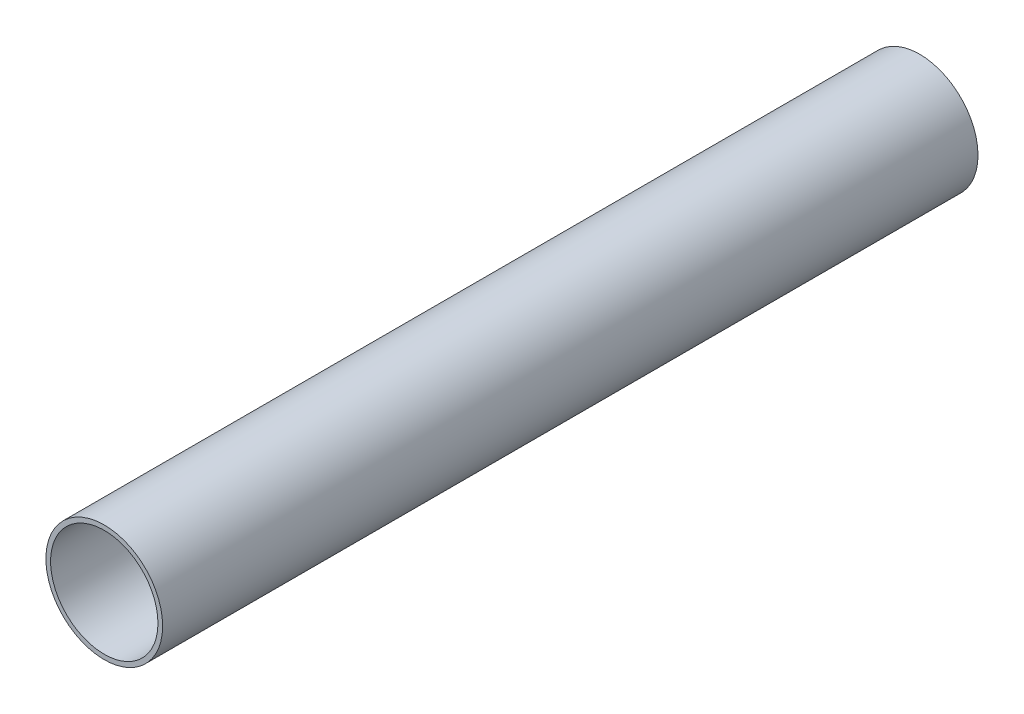
from build123d import *

# Parameters (mm, degrees)
SKETCH1_R           = 25
SKETCH1_R_2         = 23
BOSS_EXTRUDE1_DEPTH = 349.25


with BuildPart() as part:
    # Sketch1 → Boss-Extrude1 (new body)
    with BuildSketch(Plane.XY):
        Circle(SKETCH1_R)
        Circle(SKETCH1_R_2, mode=Mode.SUBTRACT)
    extrude(amount=BOSS_EXTRUDE1_DEPTH)


solid = part.part
